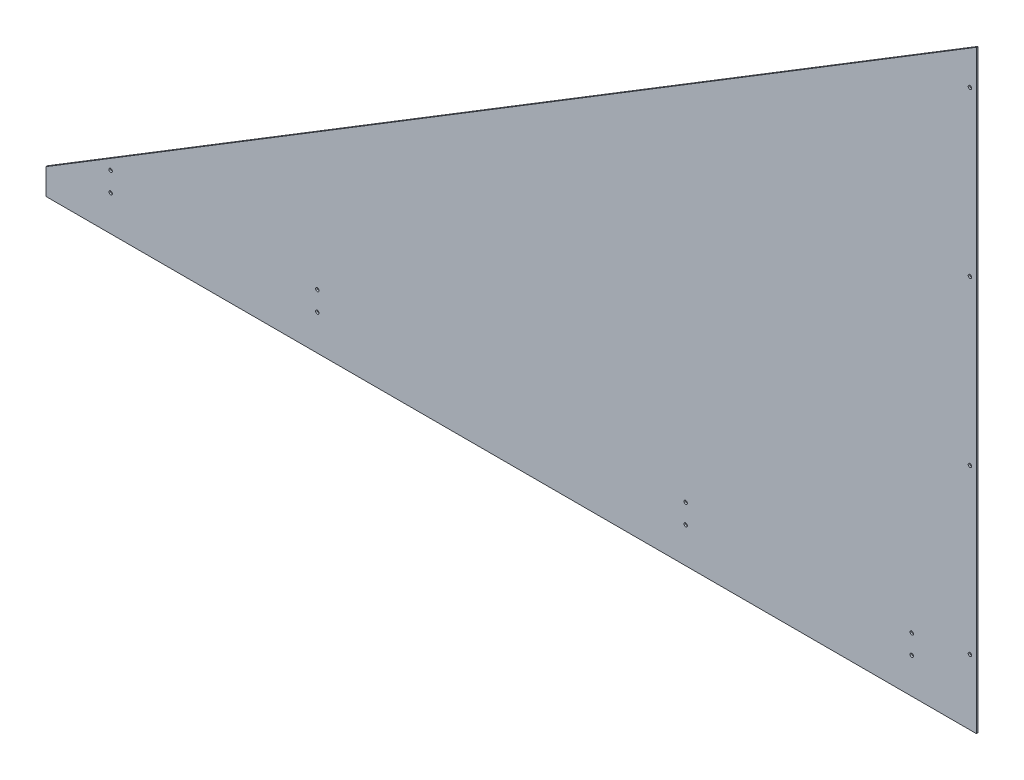
from build123d import *

# Parameters (mm, degrees)
BOSS_EXTRUDE1_DEPTH     = 3.175
F_1_4_CLEARANCE_HOLE1_D = 6.7564
SKETCH7_W               = 1828.8
SKETCH7_H               = 50.8
BOSS_EXTRUDE3_DEPTH     = 3.175


with BuildPart() as part:
    # Sketch1 → Boss-Extrude1 (new body)
    with BuildSketch(Plane.XY):
        Polygon((0, 0), (1828.8, 1117.6), (1828.8, 0), align=None)
    extrude(amount=BOSS_EXTRUDE1_DEPTH)

    # 1/4 Clearance Hole1 (through all)
    with Locations(Plane(origin=(0, 0, 0), x_dir=(-1, 0, 0), z_dir=(0, 0, -1))):
        with Locations((-1816.1, 77.7875), (-1816.1, 399.520833333), (-1816.1, 721.254166667), (-1816.1, 1042.9875), (-1701.8, 19.05), (-1701.8, 57.15), (-1257.3, 57.15), (-1257.3, 19.05), (-533.4, 57.15), (-533.4, 19.05), (-127, 57.15), (-127, 19.05)):
            Hole(F_1_4_CLEARANCE_HOLE1_D / 2)

    # Sketch7 → Boss-Extrude3 (add)
    with BuildSketch(Plane(origin=(0, 0, 0), x_dir=(-1, 0, 0), z_dir=(0, 0, -1))):
        with Locations((-914.4, -25.4)):
            Rectangle(SKETCH7_W, SKETCH7_H)
    extrude(amount=-BOSS_EXTRUDE3_DEPTH)


solid = part.part
